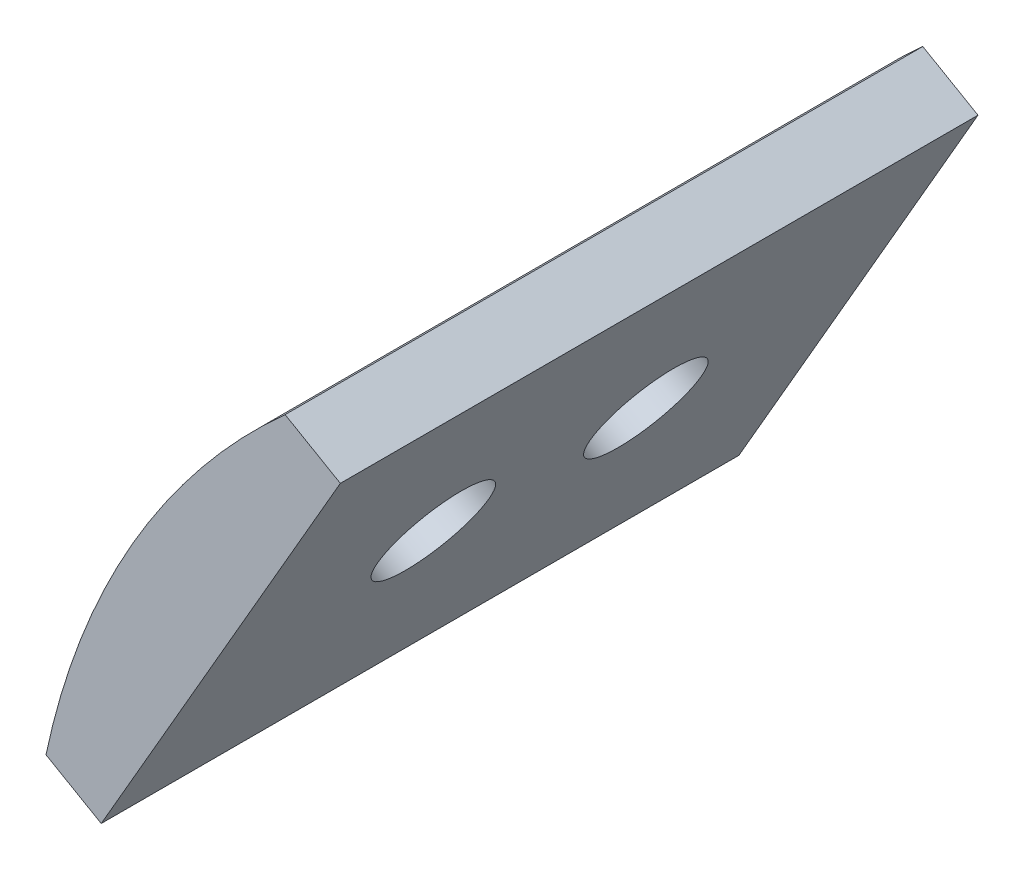
from build123d import *

# Parameters (mm, degrees)
ESTRUSIONE_ESTRUSIONE1_DEPTH = 20
SCHIZZO3_R                   = 1.75
TAGLIO_ESTRUSIONE1_DEPTH     = 23.538199536
SCHIZZO3_3_R                 = 3.15
SCHIZZO3_3_R_2               = 1.75
TAGLIO_ESTRUSIONE2_DEPTH     = 1
SMUSSO2_SIZE                 = 1.3


with BuildPart() as part:
    # Schizzo2 → Estrusione-Estrusione1 (new body)
    with BuildSketch(Plane.XY):
        with BuildLine():
            Line((-5.767949192, 11.990381057), (-7.5, 12.990381057))
            ThreePointArc((-7.5, 12.990381057), (-12.285264352, 7.092900681), (-15, 0))
            Line((-15, 0), (-13.267949192, -1))
            Line((-13.267949192, -1), (-5.767949192, 11.990381057))
        make_face()
    extrude(amount=ESTRUSIONE_ESTRUSIONE1_DEPTH)

    # Schizzo3 → Taglio-Estrusione1 (cut, through all)
    with BuildSketch(Plane(origin=(-12.285264352, 7.092900681, 0), x_dir=(0, 0, 1), z_dir=(-0.86602540378444, 0.49999999999999756, 0))):
        with Locations((6.666666667, 0)):
            Circle(SCHIZZO3_R)
        with Locations((13.333333333, 0)):
            Circle(SCHIZZO3_R)
    extrude(amount=-TAGLIO_ESTRUSIONE1_DEPTH, mode=Mode.SUBTRACT)

    # Schizzo3_3 → Taglio-Estrusione2 (cut)
    # profile 1 of 2: a face of its own
    with BuildSketch(Plane(origin=(-12.285264352, 7.092900681, 0), x_dir=(0, 0, 1), z_dir=(-0.86602540378444, 0.49999999999999756, 0))):
        with Locations((6.666666667, 0)):
            Circle(SCHIZZO3_3_R)
        with Locations((6.666666667, 0)):
            Circle(SCHIZZO3_3_R_2, mode=Mode.SUBTRACT)
    # profile 2 of 2: a face of its own
    with BuildSketch(Plane(origin=(-12.285264352, 7.092900681, 0), x_dir=(0, 0, 1), z_dir=(-0.86602540378444, 0.49999999999999756, 0))):
        with Locations((13.333333333, 0)):
            Circle(SCHIZZO3_3_R)
        with Locations((13.333333333, 0)):
            Circle(SCHIZZO3_3_R_2, mode=Mode.SUBTRACT)
    extrude(amount=-TAGLIO_ESTRUSIONE2_DEPTH, mode=Mode.SUBTRACT)

    # Smusso2
    smusso2_edges = [part.edges().sort_by_distance(p)[0] for p in [
        (-11.419238948, 6.592900681, 4.916666667),
        (-11.419238948, 6.592900681, 11.583333333),
    ]]
    chamfer(smusso2_edges, length=SMUSSO2_SIZE)


solid = part.part
